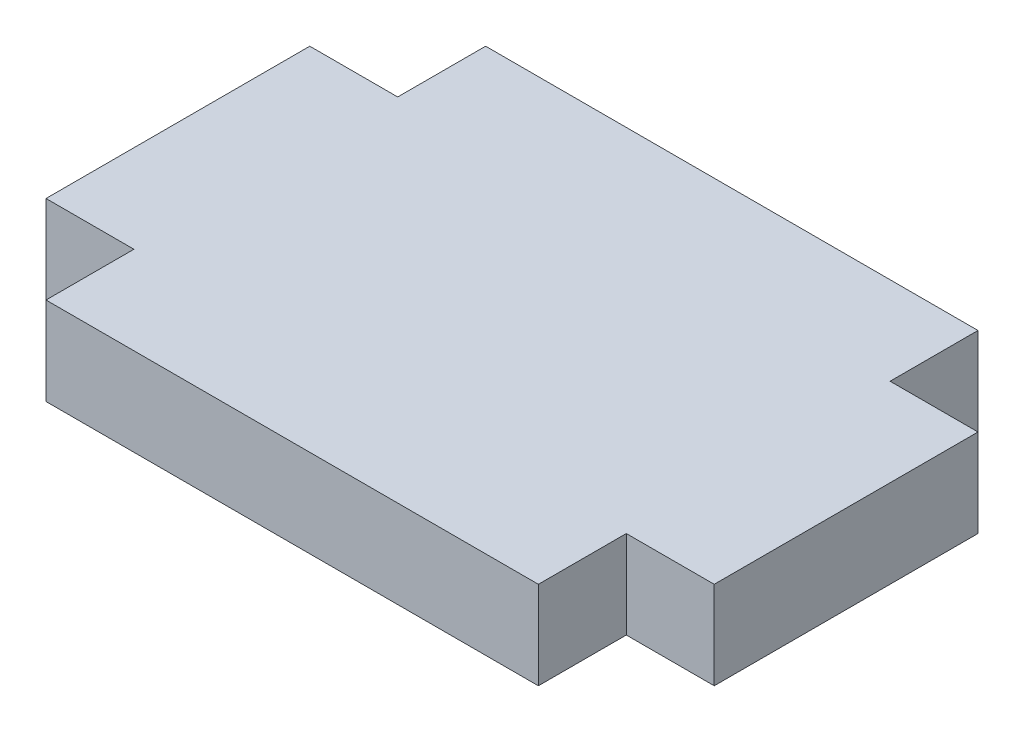
from build123d import *

# Parameters (mm, degrees)
BOSS_EXTRUDE1_DEPTH = 3.175


with BuildPart() as part:
    # Sketch1 → Boss-Extrude1 (new body)
    with BuildSketch(Plane(origin=(0, 0, 0), x_dir=(1, 0, 0), z_dir=(0, 1, 0))):
        Polygon((-8.89, 7.9375), (8.89, 7.9375), (8.89, 4.7625), (12.065, 4.7625), (12.065, -4.7625), (8.89, -4.7625), (8.89, -7.9375), (-8.89, -7.9375), (-8.89, -4.7625), (-12.065, -4.7625), (-12.065, 4.7625), (-8.89, 4.7625), align=None)
    extrude(amount=BOSS_EXTRUDE1_DEPTH)


solid = part.part
